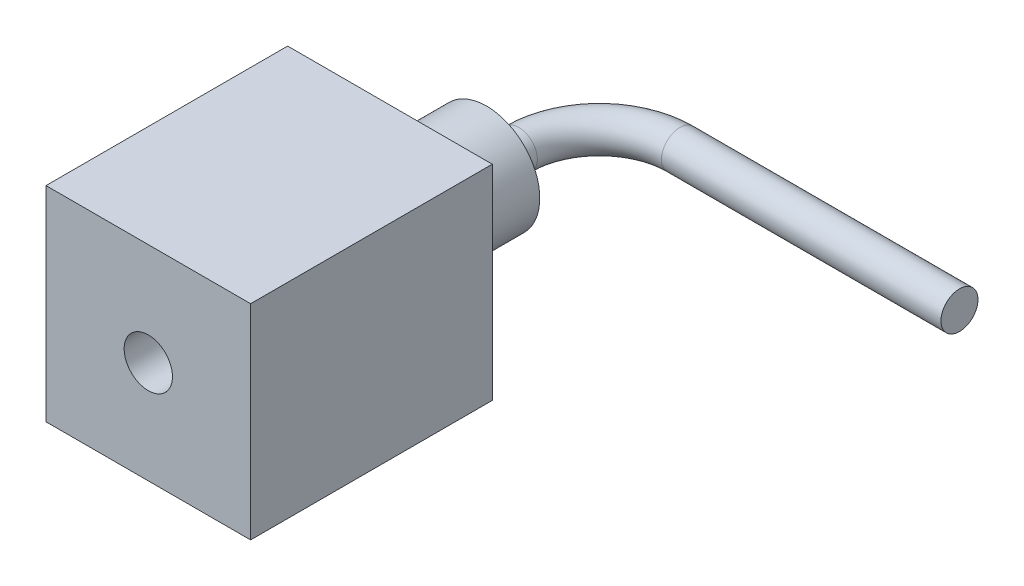
from build123d import *

# Parameters (mm, degrees)
SKETCH1_W           = 2.54
SKETCH1_H           = 2.54
BOSS_EXTRUDE1_DEPTH = 3
SKETCH2_R           = 0.66
BOSS_EXTRUDE2_DEPTH = 1.2
SKETCH4_R           = 0.3
CUT_EXTRUDE1_DEPTH  = 4
SKETCH3_R           = 0.23


with BuildPart() as part:
    # Sketch1 → Boss-Extrude1 (new body)
    with BuildSketch(Plane.XY):
        Rectangle(SKETCH1_W, SKETCH1_H)
    extrude(amount=BOSS_EXTRUDE1_DEPTH)

    # Sketch2 → Boss-Extrude2 (add)
    with BuildSketch(Plane(origin=(0, 0, 0), x_dir=(-1, 0, 0), z_dir=(0, 0, -1))):
        Circle(SKETCH2_R)
    extrude(amount=BOSS_EXTRUDE2_DEPTH)

    # Sketch4 → Cut-Extrude1 (cut)
    with BuildSketch(Plane.XY.offset(3)):
        Circle(SKETCH4_R)
    extrude(amount=-CUT_EXTRUDE1_DEPTH, mode=Mode.SUBTRACT)

    # Sweep1: sweep along a path in Sketch5
    with BuildLine(Plane(origin=(0, 0, 0), x_dir=(1, 0, 0), z_dir=(0, 1, 0))) as sweep1_path:
        Line((0, 1.2), (0, 1.6))
        ThreePointArc((0, 1.6), (0.292893219, 2.307106781), (1, 2.6))
        Line((1, 2.6), (4.47, 2.6))
    # Sketch3 → Sweep1 (sweep)
    with BuildSketch(Plane(origin=(0, 0, -1.2), x_dir=(-1, 0, 0), z_dir=(0, 0, -1))):
        Circle(SKETCH3_R)
    sweep(path=sweep1_path.line)


solid = part.part
